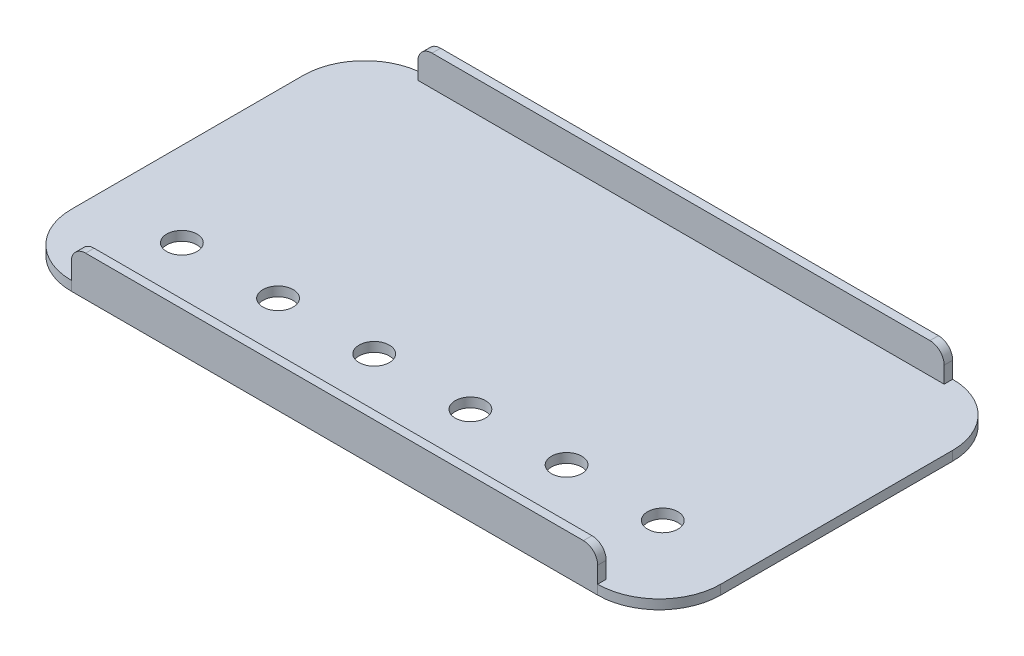
from build123d import *

# Parameters (mm, degrees)
BOSS_EXTRUDE1_DEPTH = 1
SKETCH3_W           = 55.6
SKETCH3_H           = 0.9
BOSS_EXTRUDE2_DEPTH = 3.24
FILLET1_R           = 1.5
FILLET2_R           = 1.5
FILLET3_R           = 1.5
FILLET4_R           = 1.5
CUT_EXTRUDE2_REACH  = 3
SKETCH5_R           = 1.6


with BuildPart() as part:
    # Sketch1 → Boss-Extrude1 (new body)
    with BuildSketch(Plane(origin=(0, 0, 0), x_dir=(1, 0, 0), z_dir=(0, 1, 0))):
        with BuildLine():
            Line((27.8, -18.75), (-27.8, -18.75))
            ThreePointArc((-27.8, -18.75), (-32.396194078, -16.846194078), (-34.3, -12.25))
            Line((-34.3, -12.25), (-34.3, 12.25))
            ThreePointArc((-34.3, 12.25), (-32.396194078, 16.846194078), (-27.8, 18.75))
            Line((-27.8, 18.75), (27.8, 18.75))
            ThreePointArc((27.8, 18.75), (32.396194078, 16.846194078), (34.3, 12.25))
            Line((34.3, 12.25), (34.3, -12.25))
            ThreePointArc((34.3, -12.25), (32.396194078, -16.846194078), (27.8, -18.75))
        make_face()
    extrude(amount=BOSS_EXTRUDE1_DEPTH)

    # Sketch3 → Boss-Extrude2 (add)
    with BuildSketch(Plane(origin=(0, 1, 0), x_dir=(1, 0, 0), z_dir=(0, 1, 0))):
        with Locations((0, -18.3)):
            Rectangle(SKETCH3_W, SKETCH3_H)
        with Locations((0, 18.3)):
            Rectangle(SKETCH3_W, SKETCH3_H)
    extrude(amount=BOSS_EXTRUDE2_DEPTH)

    # Fillet1
    fillet1_edges = [part.edges().sort_by_distance(p)[0] for p in [
        (-27.8, 4.24, 18.3),
    ]]
    fillet(fillet1_edges, radius=FILLET1_R)

    # Fillet2
    fillet2_edges = [part.edges().sort_by_distance(p)[0] for p in [
        (27.8, 4.24, 18.3),
    ]]
    fillet(fillet2_edges, radius=FILLET2_R)

    # Fillet3
    fillet3_edges = [part.edges().sort_by_distance(p)[0] for p in [
        (27.8, 4.24, -18.3),
    ]]
    fillet(fillet3_edges, radius=FILLET3_R)

    # Fillet4
    fillet4_edges = [part.edges().sort_by_distance(p)[0] for p in [
        (-27.8, 4.24, -18.3),
    ]]
    fillet(fillet4_edges, radius=FILLET4_R)

    # Sketch5 → Cut-Extrude2 (cut, up to next)
    with BuildSketch(Plane(origin=(0, 1, 0), x_dir=(1, 0, 0), z_dir=(0, 1, 0)), mode=Mode.PRIVATE) as cut_extrude2_sk1:
        with Locations((-25.4, -9.4746)):
            Circle(SKETCH5_R)
    cut_extrude2_tool1 = extrude(cut_extrude2_sk1.sketch, amount=-CUT_EXTRUDE2_REACH, mode=Mode.PRIVATE) & part.part
    add(cut_extrude2_tool1.solids().sort_by_distance((-25.4, 1, 9.4746))[0], mode=Mode.SUBTRACT)
    # Sketch5 → Cut-Extrude2 (cut, up to next)
    with BuildSketch(Plane(origin=(0, 1, 0), x_dir=(1, 0, 0), z_dir=(0, 1, 0)), mode=Mode.PRIVATE) as cut_extrude2_sk2:
        with Locations((-15.24, -9.4746)):
            Circle(SKETCH5_R)
    cut_extrude2_tool2 = extrude(cut_extrude2_sk2.sketch, amount=-CUT_EXTRUDE2_REACH, mode=Mode.PRIVATE) & part.part
    add(cut_extrude2_tool2.solids().sort_by_distance((-15.24, 1, 9.4746))[0], mode=Mode.SUBTRACT)
    # Sketch5 → Cut-Extrude2 (cut, up to next)
    with BuildSketch(Plane(origin=(0, 1, 0), x_dir=(1, 0, 0), z_dir=(0, 1, 0)), mode=Mode.PRIVATE) as cut_extrude2_sk3:
        with Locations((-5.08, -9.4746)):
            Circle(SKETCH5_R)
    cut_extrude2_tool3 = extrude(cut_extrude2_sk3.sketch, amount=-CUT_EXTRUDE2_REACH, mode=Mode.PRIVATE) & part.part
    add(cut_extrude2_tool3.solids().sort_by_distance((-5.08, 1, 9.4746))[0], mode=Mode.SUBTRACT)
    # Sketch5 → Cut-Extrude2 (cut, up to next)
    with BuildSketch(Plane(origin=(0, 1, 0), x_dir=(1, 0, 0), z_dir=(0, 1, 0)), mode=Mode.PRIVATE) as cut_extrude2_sk4:
        with Locations((5.08, -9.4746)):
            Circle(SKETCH5_R)
    cut_extrude2_tool4 = extrude(cut_extrude2_sk4.sketch, amount=-CUT_EXTRUDE2_REACH, mode=Mode.PRIVATE) & part.part
    add(cut_extrude2_tool4.solids().sort_by_distance((5.08, 1, 9.4746))[0], mode=Mode.SUBTRACT)
    # Sketch5 → Cut-Extrude2 (cut, up to next)
    with BuildSketch(Plane(origin=(0, 1, 0), x_dir=(1, 0, 0), z_dir=(0, 1, 0)), mode=Mode.PRIVATE) as cut_extrude2_sk5:
        with Locations((15.24, -9.4746)):
            Circle(SKETCH5_R)
    cut_extrude2_tool5 = extrude(cut_extrude2_sk5.sketch, amount=-CUT_EXTRUDE2_REACH, mode=Mode.PRIVATE) & part.part
    add(cut_extrude2_tool5.solids().sort_by_distance((15.24, 1, 9.4746))[0], mode=Mode.SUBTRACT)
    # Sketch5 → Cut-Extrude2 (cut, up to next)
    with BuildSketch(Plane(origin=(0, 1, 0), x_dir=(1, 0, 0), z_dir=(0, 1, 0)), mode=Mode.PRIVATE) as cut_extrude2_sk6:
        with Locations((25.4, -9.4746)):
            Circle(SKETCH5_R)
    cut_extrude2_tool6 = extrude(cut_extrude2_sk6.sketch, amount=-CUT_EXTRUDE2_REACH, mode=Mode.PRIVATE) & part.part
    add(cut_extrude2_tool6.solids().sort_by_distance((25.4, 1, 9.4746))[0], mode=Mode.SUBTRACT)


solid = part.part
